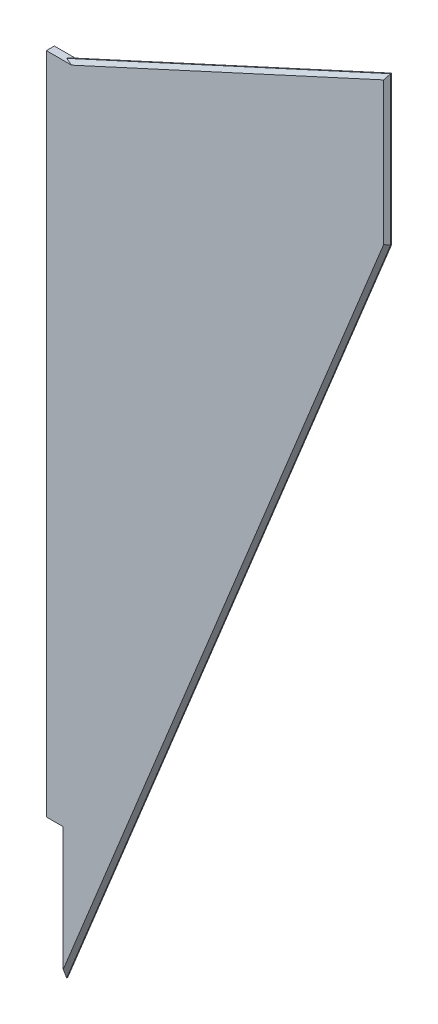
from build123d import *

# Parameters (mm, degrees)
BOSS_EXTRUDE1_DEPTH = 3
SKETCH2_W           = 3
SKETCH2_H           = 250.046113764
BOSS_EXTRUDE2_DEPTH = 6.35
CHAMFER1_SIZE       = 1.3
CHAMFER2_SIZE       = 1.3
CHAMFER3_SIZE       = 1.3


with BuildPart() as part:
    # Sketch1 → Boss-Extrude1 (new body)
    with BuildSketch(Plane.XY):
        Polygon((60, 2660), (59.981247069, 2660), (59.981247069, 2359.953886236), (182, 2660), (182, 2716), align=None)
    extrude(amount=BOSS_EXTRUDE1_DEPTH)

    # Sketch2 → Boss-Extrude2 (add)
    with BuildSketch(Plane.ZY.offset(-59.981247069)):
        with Locations((1.5, 2534.976943118)):
            Rectangle(SKETCH2_W, SKETCH2_H)
    extrude(amount=BOSS_EXTRUDE2_DEPTH)

    # Chamfer1
    chamfer1_edges = [part.edges().sort_by_distance(p)[0] for p in [
        (120.990623535, 2509.976943118, 3),
        (120.990623535, 2509.976943118, 0),
    ]]
    chamfer(chamfer1_edges, length=CHAMFER1_SIZE)

    # Chamfer2
    chamfer2_edges = [part.edges().sort_by_distance(p)[0] for p in [
        (121, 2688, 3),
        (121, 2688, 0),
    ]]
    chamfer(chamfer2_edges, length=CHAMFER2_SIZE)

    # Chamfer3
    chamfer3_edges = [part.edges().sort_by_distance(p)[0] for p in [
        (182, 2689.010267295, 0),
        (182, 2689.010267295, 3),
    ]]
    chamfer(chamfer3_edges, length=CHAMFER3_SIZE)


solid = part.part
